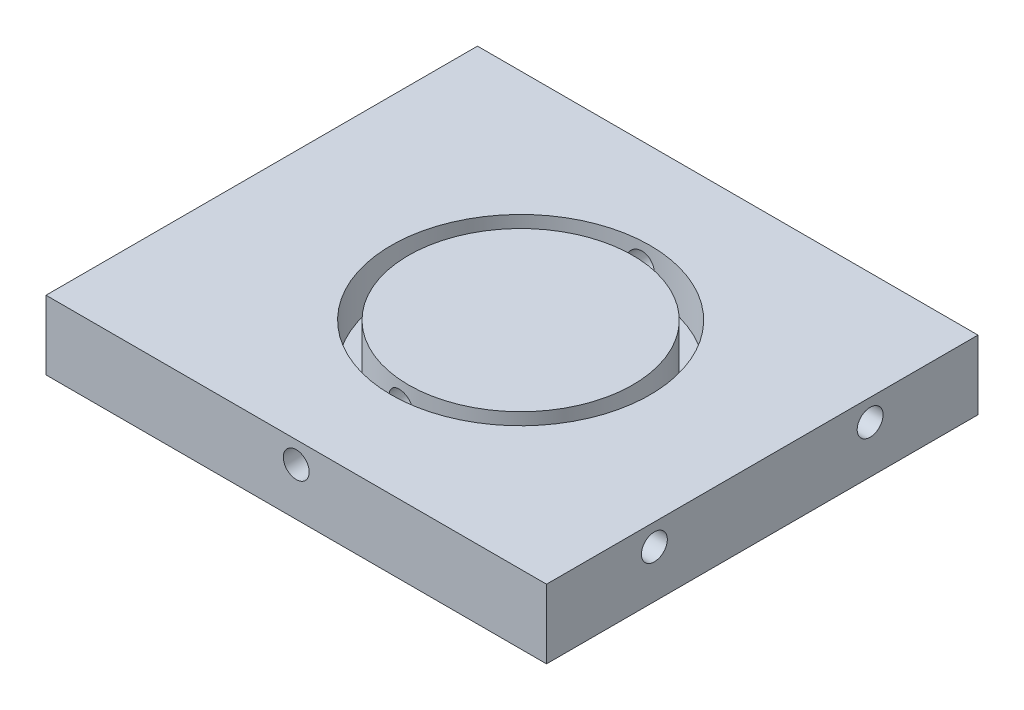
from build123d import *

# Parameters (mm, degrees)
ESQUISSE1_W             = 58
ESQUISSE1_H             = 8
BOSS_EXTRU_1_DEPTH      = 50
ESQUISSE2_R             = 15
ESQUISSE2_R_2           = 13
ENL_V_MAT_EXTRU_1_DEPTH = 5
ESQUISSE3_R             = 1.5
ENL_V_MAT_EXTRU_2_DEPTH = 10
ESQUISSE4_R             = 1.5
ENL_V_MAT_EXTRU_3_DEPTH = 10
ESQUISSE5_R             = 1.5
ENL_V_MAT_EXTRU_4_DEPTH = 51


with BuildPart() as part:
    # Esquisse1 → Boss.-Extru.1 (new body)
    with BuildSketch(Plane.XY):
        with Locations((23.5, -49)):
            Rectangle(ESQUISSE1_W, ESQUISSE1_H)
    extrude(amount=BOSS_EXTRU_1_DEPTH)

    # Esquisse2 → Enlèv. mat.-Extru.1 (cut)
    with BuildSketch(Plane(origin=(0, -45, 0), x_dir=(-1, 0, 0), z_dir=(0, 1, 0))):
        with Locations((-24.5, 25)):
            Circle(ESQUISSE2_R)
        with Locations((-24.5, 25)):
            Circle(ESQUISSE2_R_2, mode=Mode.SUBTRACT)
    extrude(amount=-ENL_V_MAT_EXTRU_1_DEPTH, mode=Mode.SUBTRACT)

    # Esquisse3 → Enlèv. mat.-Extru.2 (cut)
    with BuildSketch(Plane.ZY.offset(5.5)):
        with Locations((12.5, -47.5)):
            Circle(ESQUISSE3_R)
        with Locations((37.5, -47.5)):
            Circle(ESQUISSE3_R)
    extrude(amount=-ENL_V_MAT_EXTRU_2_DEPTH, mode=Mode.SUBTRACT)

    # Esquisse4 → Enlèv. mat.-Extru.3 (cut)
    with BuildSketch(Plane(origin=(52.5, 0, 0), x_dir=(0, 0, -1), z_dir=(1, 0, 0))):
        with Locations((-37.5, -47.5)):
            Circle(ESQUISSE4_R)
        with Locations((-12.5, -47.5)):
            Circle(ESQUISSE4_R)
    extrude(amount=-ENL_V_MAT_EXTRU_3_DEPTH, mode=Mode.SUBTRACT)

    # Esquisse5 → Enlèv. mat.-Extru.4 (cut, through all)
    with BuildSketch(Plane(origin=(0, 0, 0), x_dir=(-1, 0, 0), z_dir=(0, 0, -1))):
        with Locations((-23.5, -47.5)):
            Circle(ESQUISSE5_R)
    extrude(amount=-ENL_V_MAT_EXTRU_4_DEPTH, mode=Mode.SUBTRACT)


solid = part.part
